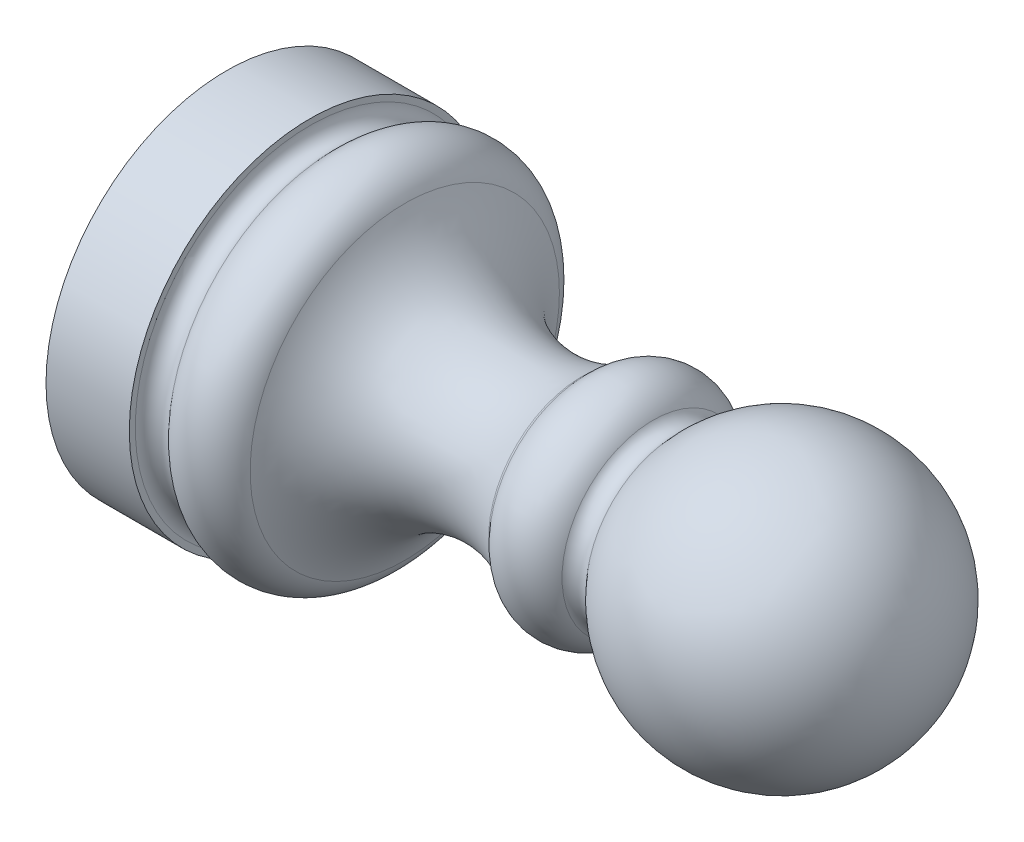
from build123d import *


with BuildPart() as part:
    # Sketch1 → Revolve1 (revolve)
    with BuildSketch(Plane.XY):
        with BuildLine():
            Line((0, 0), (0, -6.5))
            Line((0, -6.5), (3, -6.5))
            Line((3, -6.5), (3, -6.285575219))
            ThreePointArc((3, -6.285575219), (3.328989928, -5.815728909), (3.883022222, -5.964181415))
            ThreePointArc((3.883022222, -5.964181415), (5.263334015, -6.482068045), (6.420266384, -5.568298544))
            ThreePointArc((6.420266384, -5.568298544), (9.10425727, -3.023724025), (12.788338772, -3.34962285))
            ThreePointArc((12.788338772, -3.34962285), (12.862613771, -3.400650496), (12.926523227, -3.464181415))
            ThreePointArc((12.926523227, -3.464181415), (14.190984062, -3.995554809), (15.358964145, -3.27649889))
            ThreePointArc((15.358964145, -3.27649889), (15.748290839, -3.036813584), (16.169777784, -3.213938048))
            ThreePointArc((16.169777784, -3.213938048), (21.710100717, -4.698463104), (25, 0))
            Line((25, 0), (0, 0))
        make_face()
    revolve(axis=Axis((0, 0, 0), (-1, 0, 0)))


solid = part.part
